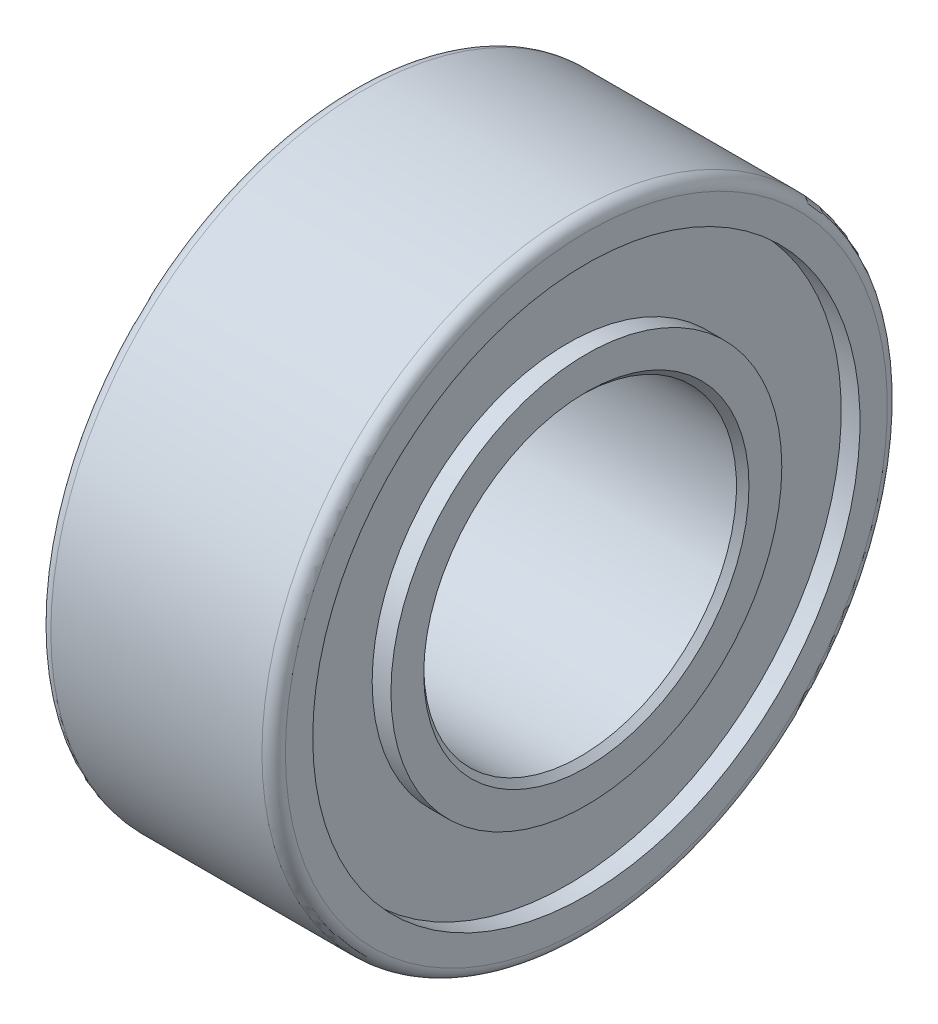
from build123d import *


with BuildPart() as part:
    # Sketch1 → Revolve1 (revolve)
    with BuildSketch(Plane(origin=(0, 0, 0), x_dir=(-1, 0, 0), z_dir=(0, 0, -1))):
        with BuildLine():
            Line((-2.38125, 3.302), (-2.25425, 3.175))
            Line((-2.25425, 3.175), (2.25425, 3.175))
            Line((2.25425, 3.175), (2.38125, 3.302))
            Line((2.38125, 3.302), (2.38125, 3.96875))
            Line((2.38125, 3.96875), (2.00025, 3.96875))
            Line((2.00025, 3.96875), (2.00025, 5.55625))
            Line((2.00025, 5.55625), (2.38125, 5.55625))
            Line((2.38125, 5.55625), (2.38125, 6.111875))
            ThreePointArc((2.38125, 6.111875), (2.311504802, 6.280254802), (2.143125, 6.35))
            Line((2.143125, 6.35), (-2.143125, 6.35))
            ThreePointArc((-2.143125, 6.35), (-2.311504802, 6.280254802), (-2.38125, 6.111875))
            Line((-2.38125, 6.111875), (-2.38125, 5.55625))
            Line((-2.38125, 5.55625), (-2.00025, 5.55625))
            Line((-2.00025, 5.55625), (-2.00025, 3.96875))
            Line((-2.00025, 3.96875), (-2.38125, 3.96875))
            Line((-2.38125, 3.96875), (-2.38125, 3.302))
        make_face()
    revolve(axis=Axis((2.382500003, 0, 0), (-1, 0, 0)))


solid = part.part
